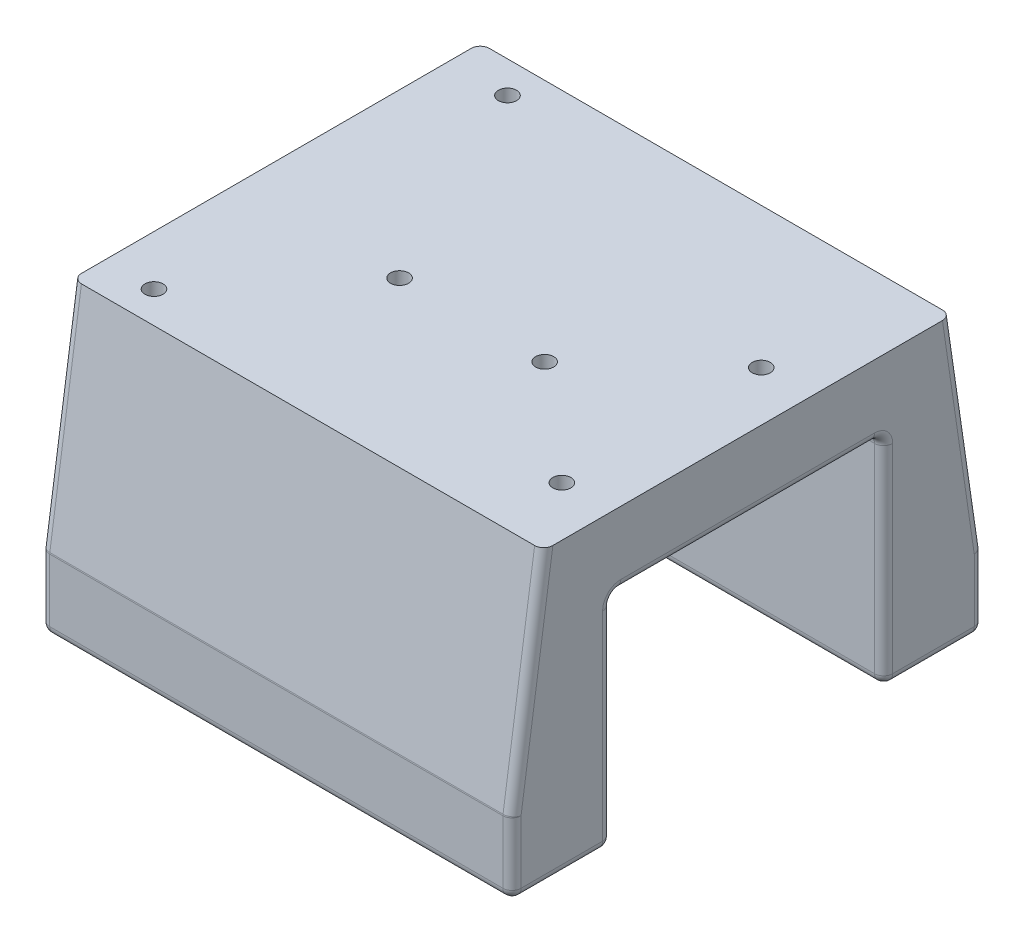
from build123d import *

# Parameters (mm, degrees)
SKETCH1_W           = 66.04
SKETCH1_H           = 10.16
BOSS_EXTRUDE1_DEPTH = 66.04
SKETCH5_W           = 66.04
SKETCH5_H           = 57.15
BOSS_EXTRUDE2_DEPTH = 30.48
SKETCH6_W           = 38.1
SKETCH6_H           = 30.48
CUT_EXTRUDE4_DEPTH  = 67.04
SKETCH7_R           = 1.27
CUT_EXTRUDE5_DEPTH  = 7.62
BOSS_EXTRUDE3_DEPTH = 66.04
FILLET1_R           = 1.27
SKETCH9_R           = 2.54
CUT_EXTRUDE6_DEPTH  = 10.16


with BuildPart() as part:
    # Sketch1 → Boss-Extrude1 (new body)
    with BuildSketch(Plane.XY):
        with Locations((33.02, 5.08)):
            Rectangle(SKETCH1_W, SKETCH1_H)
    extrude(amount=BOSS_EXTRUDE1_DEPTH)

    # Sketch5 → Boss-Extrude2 (add)
    with BuildSketch(Plane(origin=(0, 10.16, 0), x_dir=(1, 0, 0), z_dir=(0, 1, 0))):
        with Locations((33.02, -33.02)):
            Rectangle(SKETCH5_W, SKETCH5_H)
    extrude(amount=BOSS_EXTRUDE2_DEPTH)

    # Sketch6 → Cut-Extrude4 (cut, through all)
    with BuildSketch(Plane.ZY):
        with Locations((33.02, 15.24)):
            Rectangle(SKETCH6_W, SKETCH6_H)
    extrude(amount=-CUT_EXTRUDE4_DEPTH, mode=Mode.SUBTRACT)

    # Sketch7 → Cut-Extrude5 (cut)
    with BuildSketch(Plane(origin=(0, 40.64, 0), x_dir=(1, 0, 0), z_dir=(0, 1, 0))):
        with Locations((6.985, -57.15)):
            Circle(SKETCH7_R)
        with Locations((8.255, -8.89)):
            Circle(SKETCH7_R)
        with Locations((59.055, -24.13)):
            Circle(SKETCH7_R)
        with Locations((59.055, -52.07)):
            Circle(SKETCH7_R)
        with Locations((43.18, -38.608)):
            Circle(SKETCH7_R)
        with Locations((22.86, -38.608)):
            Circle(SKETCH7_R)
    extrude(amount=-CUT_EXTRUDE5_DEPTH, mode=Mode.SUBTRACT)

    # Sketch8 → Boss-Extrude3 (add)
    with BuildSketch(Plane(origin=(66.04, 0, 0), x_dir=(0, 0, -1), z_dir=(1, 0, 0))):
        Polygon((-61.595, 10.16), (-66.04, 10.16), (-61.595, 40.64), align=None)
        Polygon((-4.445, 10.16), (-4.445, 40.64), (0, 10.16), align=None)
    extrude(amount=-BOSS_EXTRUDE3_DEPTH)

    # Fillet1
    fillet1_edges = [part.edges().sort_by_distance(p)[0] for p in [
        (66.04, 5.08, 66.04),
        (33.02, 0, 66.04),
        (66.04, 0, 6.985),
        (66.04, 15.24, 52.07),
        (66.04, 30.48, 33.02),
        (66.04, 15.24, 13.97),
        (0, 0, 6.985),
        (33.02, 0, 52.07),
        (33.02, 0, 13.97),
        (0, 15.24, 13.97),
        (33.02, 30.48, 13.97),
        (0, 30.48, 33.02),
        (33.02, 30.48, 52.07),
        (0, 15.24, 52.07),
        (0, 5.08, 66.04),
        (33.02, 0, 0),
        (66.04, 5.08, 0),
        (33.02, 10.16, 0),
        (0, 5.08, 0),
        (33.02, 10.16, 66.04),
        (66.04, 25.4, 63.8175),
        (0, 25.4, 63.8175),
        (0, 0, 59.055),
        (66.04, 0, 59.055),
        (66.04, 25.4, 2.2225),
        (0, 25.4, 2.2225),
    ]]
    fillet(fillet1_edges, radius=FILLET1_R)

    # Sketch9 → Cut-Extrude6 (cut)
    with BuildSketch(Plane.XZ):
        with Locations((58.42, 58.42)):
            Circle(SKETCH9_R)
        with Locations((7.62, 58.42)):
            Circle(SKETCH9_R)
        with Locations((7.62, 7.62)):
            Circle(SKETCH9_R)
        with Locations((58.42, 7.62)):
            Circle(SKETCH9_R)
    extrude(amount=-CUT_EXTRUDE6_DEPTH, mode=Mode.SUBTRACT)


solid = part.part
